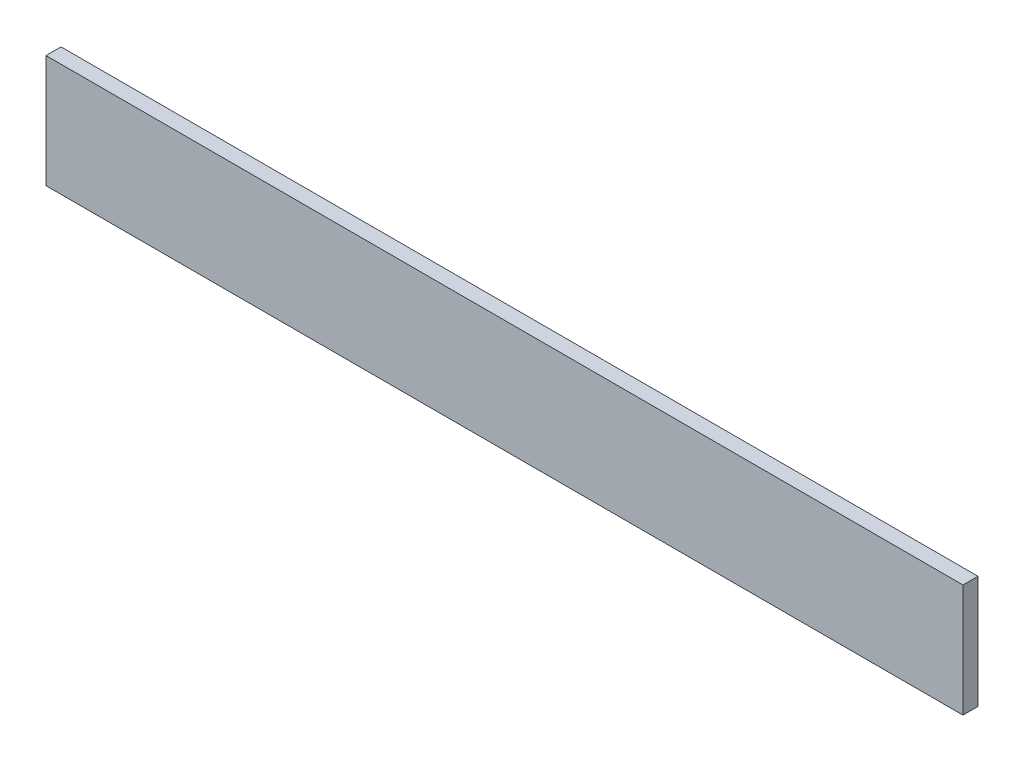
from build123d import *

# Parameters (mm, degrees)
SKETCH1_W           = 122
SKETCH1_H           = 15
BOSS_EXTRUDE1_DEPTH = 2


with BuildPart() as part:
    # Sketch1 → Boss-Extrude1 (new body)
    with BuildSketch(Plane.XY):
        with Locations((61, 7.5)):
            Rectangle(SKETCH1_W, SKETCH1_H)
    extrude(amount=BOSS_EXTRUDE1_DEPTH)


solid = part.part
